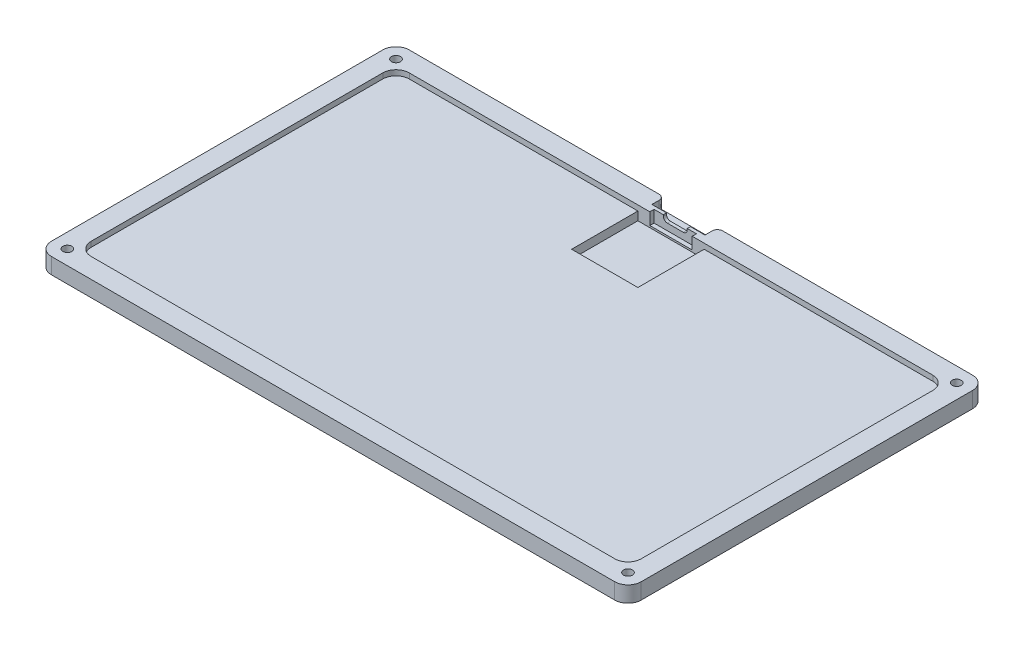
from build123d import *

# Parameters (mm, degrees)
SKETCH1_W                                      = 222.53
SKETCH1_H                                      = 135
BOSS_EXTRUDE1_DEPTH                            = 6
FILLET1_R                                      = 5
CSK_FOR_M3_FLAT_HEAD_MACHINE_SCREW1_AT_2_COUNT = 2
CSK_FOR_M3_FLAT_HEAD_MACHINE_SCREW1_AT_2_PITCH = 211.53
CSK_FOR_M3_FLAT_HEAD_MACHINE_SCREW1_AT_3_COUNT = 2
CSK_FOR_M3_FLAT_HEAD_MACHINE_SCREW1_AT_3_PITCH = 245.195719579
CSK_FOR_M3_FLAT_HEAD_MACHINE_SCREW1_AT_4_COUNT = 2
CSK_FOR_M3_FLAT_HEAD_MACHINE_SCREW1_AT_4_PITCH = 124
CHAMFER1_SIZE                                  = 0.5
PCB_CUTOUT_DEPTH                               = 2
SKETCH8_W                                      = 20
SKETCH8_H                                      = 4.7
SKETCH8_W_2                                    = 16
SKETCH8_H_2                                    = 1.6
CABLE_RELIEF_DEPTH                             = 4.5
SKETCH9_W                                      = 25
SKETCH9_H                                      = 25
PI_CUTOUT_DEPTH                                = 3.2
USB_C_CUTOUT_REACH                             = 137
MOUSE_PAD_CUTOUT_DEPTH                         = 1.8
FILLET2_R                                      = 2


with BuildPart() as part:
    # Sketch1 → Boss-Extrude1 (new body)
    with BuildSketch(Plane(origin=(0, 0, 0), x_dir=(1, 0, 0), z_dir=(0, 1, 0))):
        with Locations((111.265, 67.5)):
            Rectangle(SKETCH1_W, SKETCH1_H)
    extrude(amount=BOSS_EXTRUDE1_DEPTH)

    # Fillet1
    fillet1_edges = [part.edges().sort_by_distance(p)[0] for p in [
        (0, 3, -135),
        (222.53, 3, -135),
        (222.53, 3, 0),
        (0, 3, 0),
    ]]
    fillet(fillet1_edges, radius=FILLET1_R)

    # Sketch4 → CSK for M3 Flat Head Machine Screw1 (revolve, cut)
    with BuildSketch(Plane(origin=(5.5, 0, -129.5), x_dir=(0, 0, -1), z_dir=(1, 0, 0))):
        Polygon((0, 0), (0, 6), (1.7, 6), (1.7, 2.95), (3.15, 1.5), (3.15, 0), align=None)
    csk_for_m3_flat_head_machine_screw1 = revolve(axis=Axis((5.5, -6.35, -129.5), (0, 1, 0)), mode=Mode.SUBTRACT)

    # CSK for M3 Flat Head Machine Screw1 at 2: CSK for M3 Flat Head Machine Screw1 ×2
    with Locations(*[(i * CSK_FOR_M3_FLAT_HEAD_MACHINE_SCREW1_AT_2_PITCH, 0, 0) for i in range(1, CSK_FOR_M3_FLAT_HEAD_MACHINE_SCREW1_AT_2_COUNT)]):
        add(csk_for_m3_flat_head_machine_screw1, mode=Mode.SUBTRACT)

    # CSK for M3 Flat Head Machine Screw1 at 3: CSK for M3 Flat Head Machine Screw1 ×2
    with Locations(*[Vector(0.862698584, 0, 0.505718453) * (i * CSK_FOR_M3_FLAT_HEAD_MACHINE_SCREW1_AT_3_PITCH) for i in range(1, CSK_FOR_M3_FLAT_HEAD_MACHINE_SCREW1_AT_3_COUNT)]):
        add(csk_for_m3_flat_head_machine_screw1, mode=Mode.SUBTRACT)

    # CSK for M3 Flat Head Machine Screw1 at 4: CSK for M3 Flat Head Machine Screw1 ×2
    with Locations(*[(0, 0, i * CSK_FOR_M3_FLAT_HEAD_MACHINE_SCREW1_AT_4_PITCH) for i in range(1, CSK_FOR_M3_FLAT_HEAD_MACHINE_SCREW1_AT_4_COUNT)]):
        add(csk_for_m3_flat_head_machine_screw1, mode=Mode.SUBTRACT)

    # Chamfer1
    chamfer1_edges = [part.edges().sort_by_distance(p)[0] for p in [
        (5.5, 0, -2.35),
        (217.03, 0, -2.35),
        (217.03, 0, -126.35),
        (5.5, 0, -126.35),
    ]]
    chamfer(chamfer1_edges, length=CHAMFER1_SIZE)

    # Sketch6 → PCB Cutout (cut)
    with BuildSketch(Plane(origin=(0, 6, 0), x_dir=(1, 0, 0), z_dir=(0, 1, 0))):
        with BuildLine():
            Line((12.5, 7.5), (210.03, 7.5))
            ThreePointArc((210.03, 7.5), (213.565533906, 8.964466094), (215.03, 12.5))
            Line((215.03, 12.5), (215.03, 122.5))
            ThreePointArc((215.03, 122.5), (213.565533906, 126.035533906), (210.03, 127.5))
            Line((210.03, 127.5), (12.5, 127.5))
            ThreePointArc((12.5, 127.5), (8.964466094, 126.035533906), (7.5, 122.5))
            Line((7.5, 122.5), (7.5, 12.5))
            ThreePointArc((7.5, 12.5), (8.964466094, 8.964466094), (12.5, 7.5))
        make_face()
    extrude(amount=-PCB_CUTOUT_DEPTH, mode=Mode.SUBTRACT)

    # Sketch8 → Cable Relief (cut)
    with BuildSketch(Plane(origin=(0, 6, 0), x_dir=(1, 0, 0), z_dir=(0, 1, 0))):
        with Locations((111.265, 132.65)):
            Rectangle(SKETCH8_W, SKETCH8_H)
        with Locations((111.265, 128.3)):
            Rectangle(SKETCH8_W_2, SKETCH8_H_2)
    extrude(amount=-CABLE_RELIEF_DEPTH, mode=Mode.SUBTRACT)

    # Sketch9 → Pi Cutout (cut)
    with BuildSketch(Plane(origin=(0, 4, 0), x_dir=(1, 0, 0), z_dir=(0, 1, 0))):
        with Locations((111.265, 115)):
            Rectangle(SKETCH9_W, SKETCH9_H)
    extrude(amount=-PI_CUTOUT_DEPTH, mode=Mode.SUBTRACT)

    # Sketch7 → USB C Cutout (cut, up to next)
    with BuildSketch(Plane(origin=(0, 0, -135), x_dir=(-1, 0, 0), z_dir=(0, 0, -1)), mode=Mode.PRIVATE) as usb_c_cutout_sk1:
        with BuildLine():
            Line((-114.265, 7.8), (-108.265, 7.8))
            ThreePointArc((-108.265, 7.8), (-107.204339828, 7.360660172), (-106.765, 6.3))
            Line((-106.765, 6.3), (-106.765, 5.5))
            ThreePointArc((-106.765, 5.5), (-107.204339828, 4.439339828), (-108.265, 4))
            Line((-108.265, 4), (-114.265, 4))
            ThreePointArc((-114.265, 4), (-115.325660172, 4.439339828), (-115.765, 5.5))
            Line((-115.765, 5.5), (-115.765, 6.3))
            ThreePointArc((-115.765, 6.3), (-115.325660172, 7.360660172), (-114.265, 7.8))
        make_face()
    usb_c_cutout_tool1 = extrude(usb_c_cutout_sk1.sketch, amount=-USB_C_CUTOUT_REACH, mode=Mode.PRIVATE) & part.part
    add(usb_c_cutout_tool1.solids().sort_by_distance((111.265, 5.9, -135))[0], mode=Mode.SUBTRACT)

    # Sketch5 → Mouse Pad Cutout (cut)
    with BuildSketch(Plane.XZ):
        Polygon((127.765, -126.035533906), (213.565533906, -126.035533906), (213.565533906, -8.964466094), (8.964466094, -8.964466094), (8.964466094, -126.035533906), (94.765, -126.035533906), (94.765, -99.035533906), (127.765, -99.035533906), align=None)
    extrude(amount=-MOUSE_PAD_CUTOUT_DEPTH, mode=Mode.SUBTRACT)

    # Fillet2
    fillet2_edges = [part.edges().sort_by_distance(p)[0] for p in [
        (101.265, 3.75, -135),
        (121.265, 3.75, -135),
    ]]
    fillet(fillet2_edges, radius=FILLET2_R)


solid = part.part
